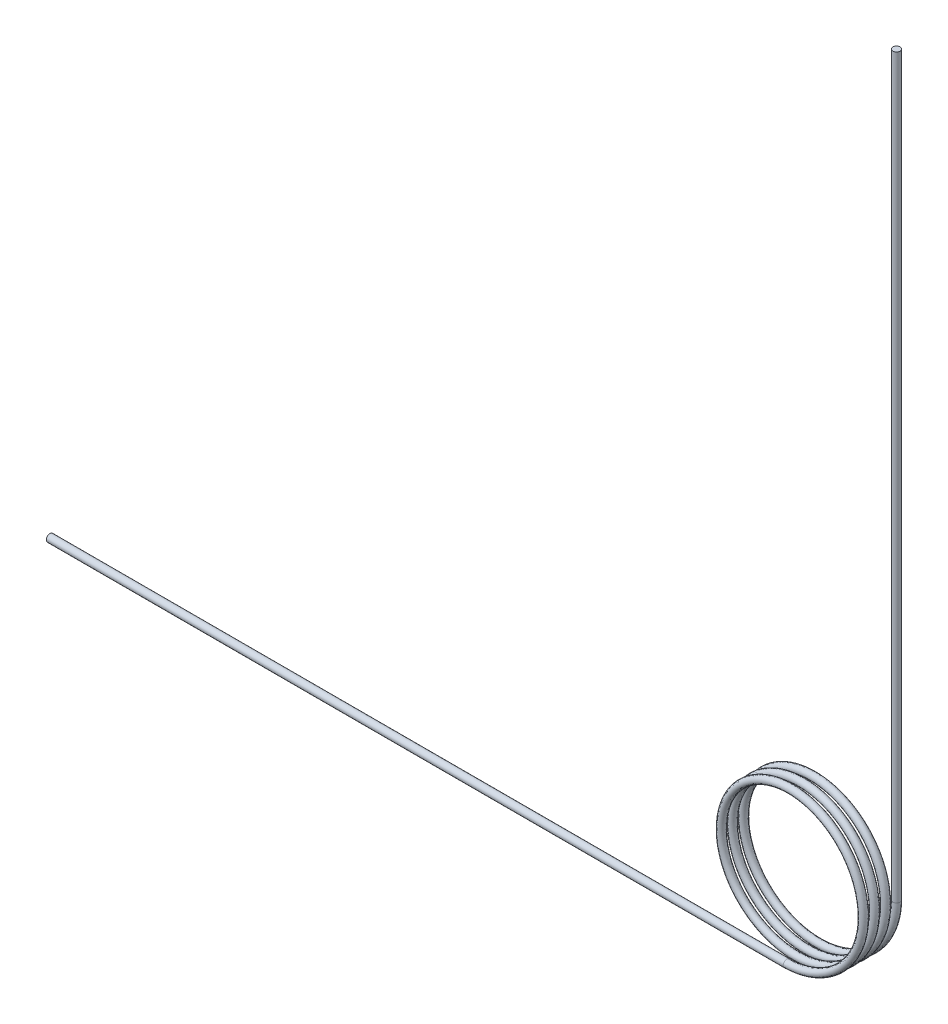
from build123d import *

# Parameters (mm, degrees)
SWEEP_1_PITCH   = 0.3
SWEEP_1_HEIGHT  = 0.975
SWEEP_1_RADIUS  = 2
SKETCH_3_R      = 0.1
SKETCH_5_R      = 0.1
EXTRUDE_2_DEPTH = 20
SKETCH_6_R      = 0.1
EXTRUDE_3_DEPTH = 20


with BuildPart() as part:
    # 扫描1: sweep along a helix
    with BuildLine() as sweep_1_path:
        Helix(SWEEP_1_PITCH, SWEEP_1_HEIGHT, SWEEP_1_RADIUS, center=(0, 0, 0), direction=(0, 0, 1), lefthand=True)
    # 草图3 → 扫描1 (sweep)
    with BuildSketch(Plane(origin=(0, 0, 0), x_dir=(1, 0, 0), z_dir=(0, 1, 0))):
        with Locations((2, 0)):
            Circle(SKETCH_3_R)
    sweep(path=sweep_1_path.line, is_frenet=True)

    # 草图5 → 凸台-拉伸2 (add)
    with BuildSketch(Plane(origin=(0, 0, 0), x_dir=(1, 0, 0), z_dir=(0, 1, 0))):
        with Locations((2, 0)):
            Circle(SKETCH_5_R)
    extrude(amount=EXTRUDE_2_DEPTH)

    # 草图6 → 凸台-拉伸3 (add)
    with BuildSketch(Plane.ZY):
        with Locations((0.975, -2)):
            Circle(SKETCH_6_R)
    extrude(amount=EXTRUDE_3_DEPTH)


solid = part.part
